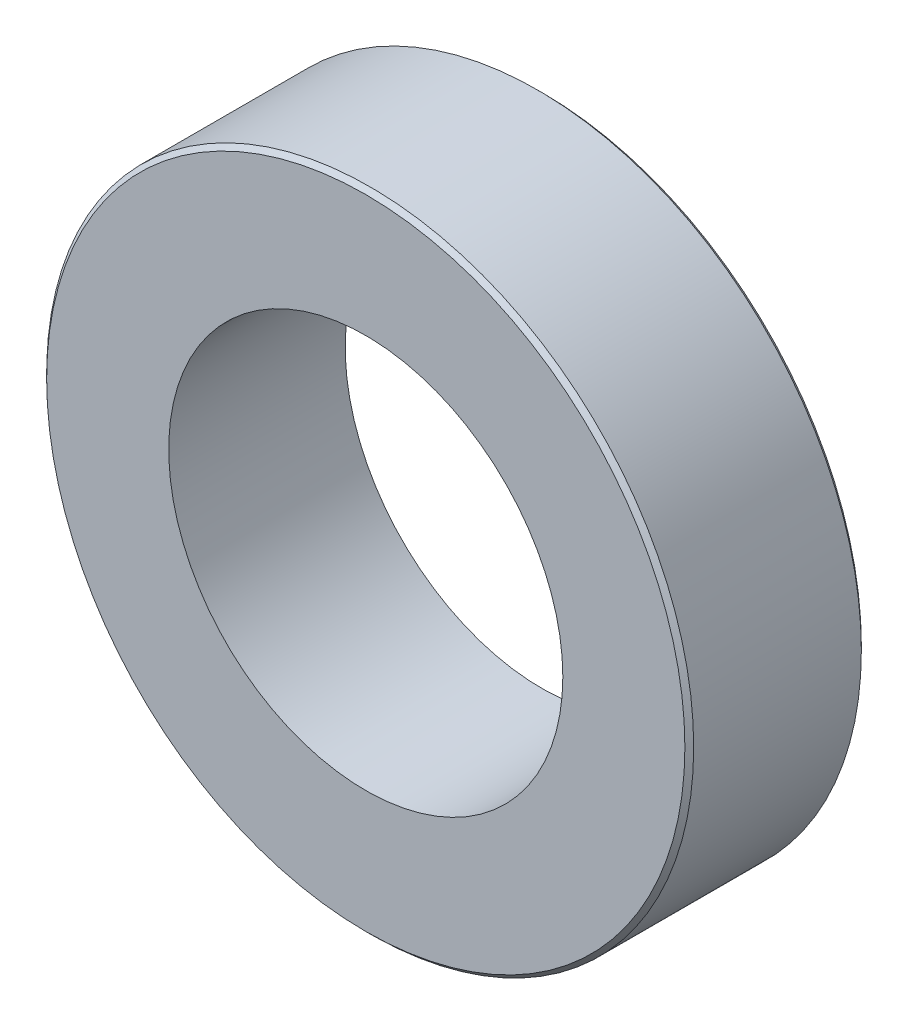
from build123d import *

# Parameters (mm, degrees)
SKETCH1_R           = 11
SKETCH1_R_2         = 6.7
BOSS_EXTRUDE1_DEPTH = 3
CHAMFER1_SIZE       = 0.15


with BuildPart() as part:
    # Sketch1 → Boss-Extrude1 (new body, symmetric)
    with BuildSketch(Plane.XY):
        Circle(SKETCH1_R)
        Circle(SKETCH1_R_2, mode=Mode.SUBTRACT)
    extrude(amount=BOSS_EXTRUDE1_DEPTH, both=True)

    # Chamfer1
    chamfer1_edges = [part.edges().sort_by_distance(p)[0] for p in [
        (-11, 0, -3),
        (-11, 0, 3),
    ]]
    chamfer(chamfer1_edges, length=CHAMFER1_SIZE)


solid = part.part
